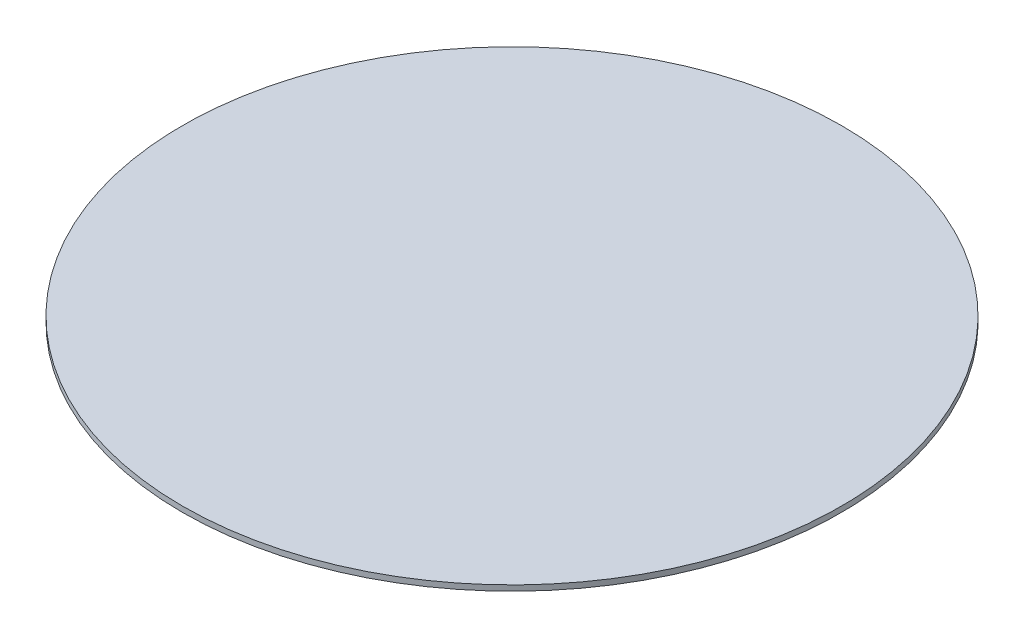
from build123d import *

# Parameters (mm, degrees)
SKIZZE1_R                       = 1200
AUFSATZ_LINEAR_AUSTRAGEN1_DEPTH = 20


with BuildPart() as part:
    # Skizze1 → Aufsatz-Linear austragen1 (new body)
    with BuildSketch(Plane(origin=(0, 0, 0), x_dir=(1, 0, 0), z_dir=(0, 1, 0))):
        with Locations(Location((0, 0, 0), (0, 0, 270))):  # turned: the seam where the file's is
            Circle(SKIZZE1_R)
    extrude(amount=AUFSATZ_LINEAR_AUSTRAGEN1_DEPTH)


solid = part.part
